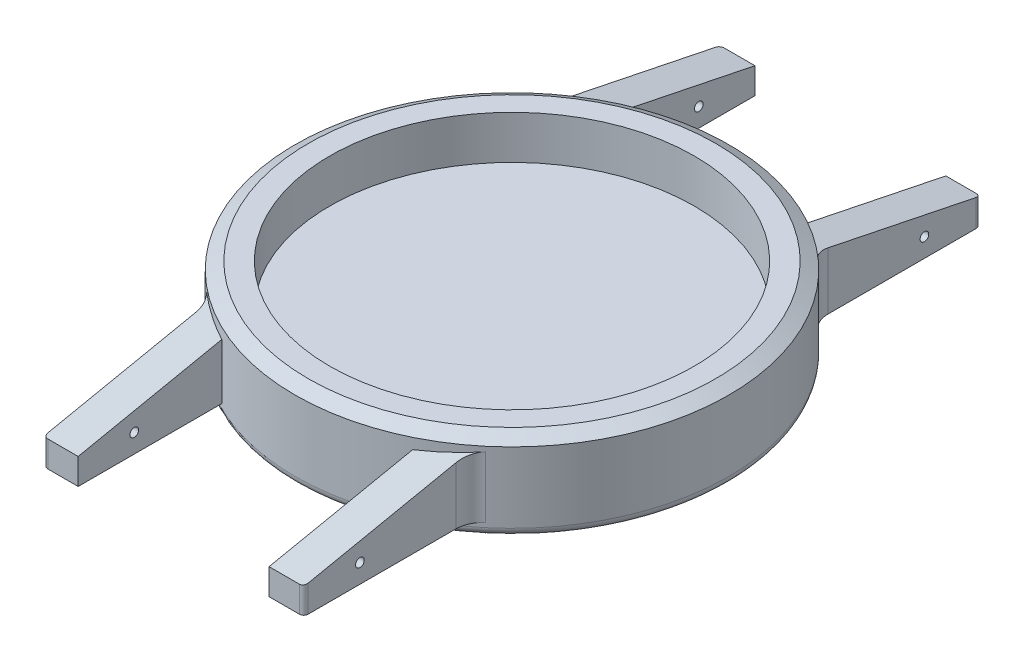
from build123d import *
from build123d.topology import SkipClean

# Parameters (mm, degrees)
SKETCH1_R                = 50
BOSS_EXTRUDE1_DEPTH      = 20
BOSS_EXTRUDE2_DEPTH      = 30
BOSS_EXTRUDE2_DEPTH_BACK = 30
CUT_EXTRUDE2_DEPTH       = 30
CHAMFER1_SIZE            = 1.75
CHAMFER1_SIZE2           = 3.031089
SKETCH5_R                = 42
CUT_EXTRUDE3_DEPTH       = 10
FILLET1_R                = 6
FILLET2_R                = 6
FILLET3_R                = 2
FILLET4_R                = 1
CUT_EXTRUDE5_DEPTH       = 20
CUT_EXTRUDE5_DEPTH_BACK  = 85
SKETCH7_R                = 1
CUT_EXTRUDE6_DEPTH       = 25
CUT_EXTRUDE6_DEPTH_BACK  = 93
SKETCH8_R                = 1


with BuildPart() as part:
    # Sketch1 → Boss-Extrude1 (new body)
    with BuildSketch(Plane(origin=(0, 0, 0), x_dir=(1, 0, 0), z_dir=(0, 1, 0))):
        Circle(SKETCH1_R)
    extrude(amount=-BOSS_EXTRUDE1_DEPTH)

    # Sketch3 → Boss-Extrude2 (add, two sides: drawn at the far end of the back side and taken through both)
    with BuildSketch(Plane(origin=(0, 0, 0), x_dir=(0, 0, -1), z_dir=(1, 0, 0)).offset(-BOSS_EXTRUDE2_DEPTH_BACK)):
        Polygon((34.980741, -17), (34.980741, -2.160126), (78, -11), (78, -17), align=None)
        Polygon((-78, -11), (-34.980741, -2.160126), (-34.980741, -17), (-78, -17), align=None)
    extrude(amount=BOSS_EXTRUDE2_DEPTH + BOSS_EXTRUDE2_DEPTH_BACK)

    # Sketch4 → Cut-Extrude2 (cut)
    with SkipClean():  # the faces are left unmerged after this step: merging them gives an invalid solid
        with BuildSketch(Plane(origin=(0, 0, 0), x_dir=(1, 0, 0), z_dir=(0, 1, 0))):
            with BuildLine():
                Line((22, 78), (-22, 78))
                Line((-22, 78), (-22, 44.899889))
                ThreePointArc((-22, 44.899889), (0, 50), (22, 44.899889))
                Line((22, 44.899889), (22, 78))
            make_face()
            with BuildLine():
                Line((-22, -78), (-22, -44.899889))
                ThreePointArc((-22, -44.899889), (0, -50), (22, -44.899889))
                Line((22, -44.899889), (22, -78))
                Line((22, -78), (-22, -78))
            make_face()
        extrude(amount=-CUT_EXTRUDE2_DEPTH, mode=Mode.SUBTRACT)

    # Chamfer1
    chamfer1_edges = [part.edges().sort_by_distance(p)[0] for p in [
        (0, 0, 50),
    ]]
    chamfer1_side = [part.faces().sort_by_distance(p)[0] for p in [
        (0, -2.700156, 50),
    ]]
    chamfer(chamfer1_edges, length=CHAMFER1_SIZE, length2=CHAMFER1_SIZE2, reference=chamfer1_side[0])

    # Sketch5 → Cut-Extrude3 (cut)
    with SkipClean():  # the faces are left unmerged after this step: merging them gives an invalid solid
        with BuildSketch(Plane(origin=(0, 0, 0), x_dir=(1, 0, 0), z_dir=(0, 1, 0))):
            Circle(SKETCH5_R)
        extrude(amount=-CUT_EXTRUDE3_DEPTH, mode=Mode.SUBTRACT)

    # Fillet1
    fillet1_edges = [part.edges().sort_by_distance(p)[0] for p in [
        (30, -10.095758, 40),
    ]]
    fillet(fillet1_edges, radius=FILLET1_R)

    # Fillet2
    fillet2_edges = [part.edges().sort_by_distance(p)[0] for p in [
        (30, -10.095758, -40),
        (-30, -10.095758, -40),
        (-30, -10.095758, 40),
    ]]
    fillet(fillet2_edges, radius=FILLET2_R)

    # Fillet3
    fillet3_edges = [part.edges().sort_by_distance(p)[0] for p in [
        (0, -20, 50),
    ]]
    fillet(fillet3_edges, radius=FILLET3_R)

    # Fillet4
    fillet4_edges = [part.edges().sort_by_distance(p)[0] for p in [
        (30, -14, 78),
        (-30, -14, 78),
        (30, -14, -78),
        (-30, -14, -78),
    ]]
    fillet(fillet4_edges, radius=FILLET4_R)

    # Sketch7 → Cut-Extrude5 (cut, two sides: drawn at the far end of the back side and taken through both)
    with SkipClean():  # the faces are left unmerged after this step: merging them gives an invalid solid
        with BuildSketch(Plane(origin=(30, 0, 0), x_dir=(0, 0, -1), z_dir=(1, 0, 0)).offset(-CUT_EXTRUDE5_DEPTH_BACK)):
            with Locations((-65.06284, -12.670795)):
                Circle(SKETCH7_R)
        extrude(amount=CUT_EXTRUDE5_DEPTH + CUT_EXTRUDE5_DEPTH_BACK, mode=Mode.SUBTRACT)

    # Sketch8 → Cut-Extrude6 (cut, two sides: drawn at the far end of the back side and taken through both)
    with SkipClean():  # the faces are left unmerged after this step: merging them gives an invalid solid
        with BuildSketch(Plane(origin=(30, 0, 0), x_dir=(0, 0, -1), z_dir=(1, 0, 0)).offset(-CUT_EXTRUDE6_DEPTH_BACK)):
            with Locations((65.06284, -12.670795)):
                Circle(SKETCH8_R)
        extrude(amount=CUT_EXTRUDE6_DEPTH + CUT_EXTRUDE6_DEPTH_BACK, mode=Mode.SUBTRACT)


solid = part.part
